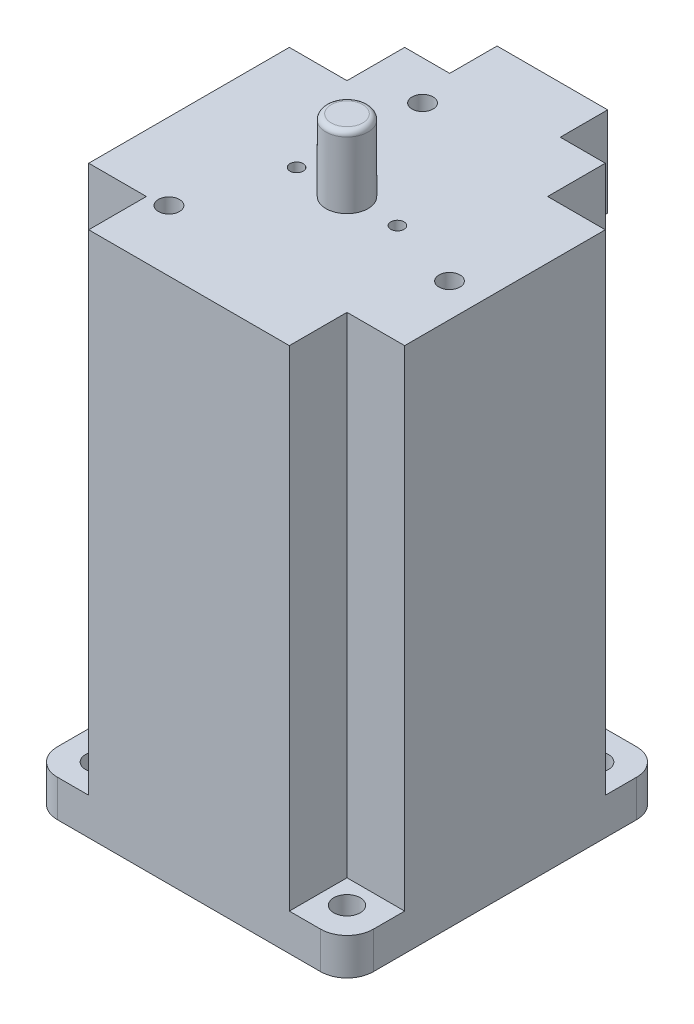
from build123d import *

# Parameters (mm, degrees)
SKETCH1_W               = 60
SKETCH1_H               = 60
BOSS_EXTRUDE1_DEPTH     = 100
SKETCH2_W               = 10.95
SKETCH2_H               = 10.95
CUT_EXTRUDE1_DEPTH      = 93
MIRROR2_COPY_1_SKETCH_W = 10.95
MIRROR2_COPY_1_SKETCH_H = 10.95
MIRROR2_COPY_1_DEPTH    = 93
SKETCH5_R               = 2.5
CUT_EXTRUDE2_DEPTH      = 93
SKETCH7_R               = 19.05
BOSS_EXTRUDE4_DEPTH     = 1.8
SKETCH8_R               = 4
BOSS_EXTRUDE5_DEPTH     = 20.4
FILLET2_R               = 5
SKETCH15_R              = 4
BOSS_EXTRUDE6_DEPTH     = 13.6
FILLET4_R               = 1
CUT_EXTRUDE4_DEPTH      = 15.5
BOSS_EXTRUDE7_DEPTH     = 9
BOSS_EXTRUDE8_DEPTH     = 9
SKETCH22_R              = 1.25
SKETCH22_R_2            = 2
CUT_EXTRUDE7_DEPTH      = 4


with BuildPart() as part:
    # Sketch1 → Boss-Extrude1 (new body)
    with BuildSketch(Plane(origin=(0, 0, 0), x_dir=(1, 0, 0), z_dir=(0, 1, 0))):
        Rectangle(SKETCH1_W, SKETCH1_H)
    extrude(amount=BOSS_EXTRUDE1_DEPTH)

    # Sketch2 → Cut-Extrude1 (cut)
    with BuildSketch(Plane(origin=(0, 100, 0), x_dir=(1, 0, 0), z_dir=(0, 1, 0))):
        with Locations((-24.525, 24.525)):
            Rectangle(SKETCH2_W, SKETCH2_H)
    cut_extrude1 = extrude(amount=-CUT_EXTRUDE1_DEPTH, mode=Mode.SUBTRACT)

    # Mirror1: Cut-Extrude1 across plane
    add(cut_extrude1.mirror(Plane(origin=(0, 0, 0), x_dir=(0, 0, 1), z_dir=(1, 0, 0))), mode=Mode.SUBTRACT)

    # Mirror2: Cut-Extrude1 across plane
    add(cut_extrude1.mirror(Plane.XY), mode=Mode.SUBTRACT)

    # Mirror2 copy 1 sketch → Mirror2 copy 1 (cut)
    with BuildSketch(Plane(origin=(0, 100, 0), x_dir=(-1, 0, 0), z_dir=(0, 1, 0))):
        with Locations((-24.525, 24.525)):
            Rectangle(MIRROR2_COPY_1_SKETCH_W, MIRROR2_COPY_1_SKETCH_H)
    extrude(amount=-MIRROR2_COPY_1_DEPTH, mode=Mode.SUBTRACT)

    # Sketch5 → Cut-Extrude2 (cut)
    with BuildSketch(Plane.XZ):
        with Locations((-23.57, -23.57)):
            Circle(SKETCH5_R)
        with Locations((23.57, -23.57)):
            Circle(SKETCH5_R)
        with Locations((23.57, 23.57)):
            Circle(SKETCH5_R)
        with Locations((-23.57, 23.57)):
            Circle(SKETCH5_R)
    extrude(amount=-CUT_EXTRUDE2_DEPTH, mode=Mode.SUBTRACT)

    # Sketch7 → Boss-Extrude4 (add)
    with BuildSketch(Plane.XZ):
        Circle(SKETCH7_R)
    extrude(amount=BOSS_EXTRUDE4_DEPTH)

    # Sketch8 → Boss-Extrude5 (add)
    with BuildSketch(Plane.XZ.offset(1.8)):
        Circle(SKETCH8_R)
    extrude(amount=BOSS_EXTRUDE5_DEPTH)

    # Fillet2
    fillet2_edges = [part.edges().sort_by_distance(p)[0] for p in [
        (-30, 3.5, -30),
        (30, 3.5, -30),
        (30, 3.5, 30),
        (-30, 3.5, 30),
    ]]
    fillet(fillet2_edges, radius=FILLET2_R)

    # Sketch15 → Boss-Extrude6 (add)
    with BuildSketch(Plane(origin=(0, 100, 0), x_dir=(1, 0, 0), z_dir=(0, 1, 0))):
        Circle(SKETCH15_R)
    extrude(amount=BOSS_EXTRUDE6_DEPTH)

    # Fillet4
    fillet4_edges = [part.edges().sort_by_distance(p)[0] for p in [
        (-4, 113.6, 0),
    ]]
    fillet(fillet4_edges, radius=FILLET4_R)

    # Sketch17 → Cut-Extrude4 (cut)
    with BuildSketch(Plane.XZ.offset(22.2)):
        with BuildLine():
            Line((-2.552821159, -3.1), (2.552821159, -3.1))
            ThreePointArc((2.552821159, -3.1), (0, -4.015830658), (-2.552821159, -3.1))
        make_face()
    extrude(amount=-CUT_EXTRUDE4_DEPTH, mode=Mode.SUBTRACT)

    # Sketch20 → Boss-Extrude7 (add)
    with BuildSketch(Plane(origin=(0, 0, -30), x_dir=(-1, 0, 0), z_dir=(0, 0, -1))):
        Polygon((0, 100), (10.5, 100), (10.5, 83), (-10.5, 83), (-10.5, 100), align=None)
    extrude(amount=BOSS_EXTRUDE7_DEPTH)

    # Sketch21 → Boss-Extrude8 (add)
    with BuildSketch(Plane.XZ.offset(-83)):
        Polygon((0, -39), (-6, -39), (-6, -34), (6, -34), (6, -39), align=None)
    extrude(amount=BOSS_EXTRUDE8_DEPTH)

    # Sketch22 → Cut-Extrude7 (cut)
    with BuildSketch(Plane(origin=(0, 100, 0), x_dir=(1, 0, 0), z_dir=(0, 1, 0))):
        with Locations((-9.575, 0)):
            Circle(SKETCH22_R)
        with Locations((9.575, 0)):
            Circle(SKETCH22_R)
        with Locations((-8.20848344, 22.552622899)):
            Circle(SKETCH22_R_2)
        with Locations((-15.426902632, -18.385066635)):
            Circle(SKETCH22_R_2)
        with Locations((23.635386072, -4.167556264)):
            Circle(SKETCH22_R_2)
    extrude(amount=-CUT_EXTRUDE7_DEPTH, mode=Mode.SUBTRACT)


solid = part.part
